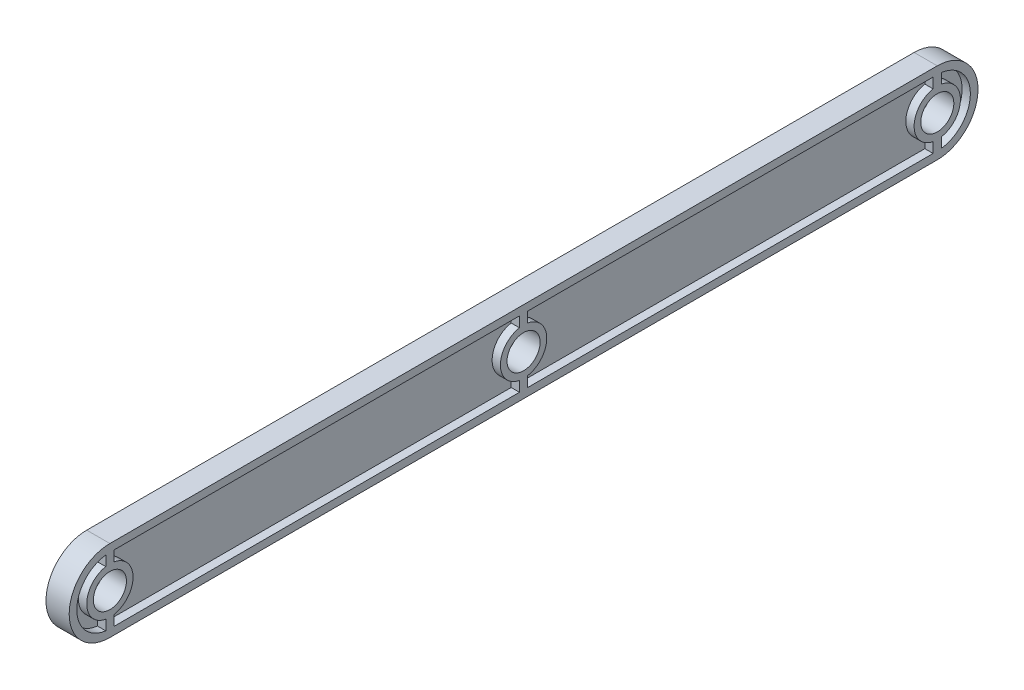
from build123d import *

# Parameters (mm, degrees)
BOSS_EXTRUDE1_DEPTH = 2
EXTRUDE_START       = 5
EXTRUDE_1_DEPTH     = 5
EXTRUDE_2_DEPTH     = 5
SKETCH_4_R          = 14
SKETCH_4_R_2        = 14.00018903
CUT_EXTRUDE_1_DEPTH = 5
SKETCH1_3_R         = 10
CUT_EXTRUDE_2_DEPTH = 15
RIB_2_REACH         = 478.571
SKETCH_5_WALLS_W    = 5
SKETCH_5_WALLS_H    = 961.14191471
SKETCH_5_WALLS_H_2  = 961.14172568


with BuildPart() as part:
    # Sketch1 → Boss-Extrude1 (new, symmetric)
    with BuildSketch(Plane(origin=(0, 0, 0), x_dir=(0, 0, -1), z_dir=(1, 0, 0))):
        with BuildLine():
            Line((451.121433311, 24.607830126), (-48.878566689, 24.607830126))
            ThreePointArc((-48.878566689, 24.607830126), (-73.486396815, 0), (-48.878566689, -24.607830126))
            Line((-48.878566689, -24.607830126), (451.121433311, -24.607830126))
            ThreePointArc((451.121433311, -24.607830126), (475.729263437, 0), (451.121433311, 24.607830126))
        make_face()
    extrude(amount=BOSS_EXTRUDE1_DEPTH, both=True)

    # Sketch 1 → Extrude 1 (add)
    with BuildSketch(Plane(origin=(2, 0, 0), x_dir=(0, 0, -1), z_dir=(1, 0, 0)).offset(EXTRUDE_START)):
        with BuildLine():
            Line((451.121433311, 24.607830126), (-48.878566689, 24.607830126))
            ThreePointArc((-48.878566689, 24.607830126), (-73.486396815, 0), (-48.878566689, -24.607830126))
            Line((-48.878566689, -24.607830126), (451.121433311, -24.607830126))
            ThreePointArc((451.121433311, -24.607830126), (475.729263437, 0), (451.121433311, 24.607830126))
        make_face()
    extrude(amount=-EXTRUDE_1_DEPTH)

    # Sketch 2 → Extrude 2 (add)
    with BuildSketch(Plane.ZY.offset(2)):
        with BuildLine():
            Line((-451.121433311, 24.607830126), (48.878566689, 24.607830126))
            ThreePointArc((48.878566689, 24.607830126), (73.486396815, 0), (48.878566689, -24.607830126))
            Line((48.878566689, -24.607830126), (-451.121433311, -24.607830126))
            ThreePointArc((-451.121433311, -24.607830126), (-475.729263437, 0), (-451.121433311, 24.607830126))
        make_face()
    extrude(amount=EXTRUDE_2_DEPTH)

    # Sketch 4 → Cut-Extrude 1 (cut)
    with BuildSketch(Plane.ZY.offset(7)):
        with BuildLine():
            Line((48.878566689, 20), (-451.121433311, 20))
            ThreePointArc((-451.121433311, 20), (-471.121433311, 0), (-451.121433311, -20))
            Line((-451.121433311, -20), (48.878566689, -20))
            ThreePointArc((48.878566689, -20), (68.878566689, 0), (48.878566689, 20))
        make_face()
        with Locations((-451.121433311, 0)):
            Circle(SKETCH_4_R, mode=Mode.SUBTRACT)
        with Locations((-201.121433311, 0)):
            Circle(SKETCH_4_R_2, mode=Mode.SUBTRACT)
        with Locations((48.878566689, 0)):
            Circle(SKETCH_4_R, mode=Mode.SUBTRACT)
    cut_extrude_1 = extrude(amount=-CUT_EXTRUDE_1_DEPTH, mode=Mode.SUBTRACT)

    # Mirror 1: Cut-Extrude 1 across plane
    add(cut_extrude_1.mirror(Plane.ZY), mode=Mode.SUBTRACT)

    # Sketch1_3 → Cut-Extrude 2 (cut, symmetric)
    with BuildSketch(Plane(origin=(0, 0, 0), x_dir=(0, 0, -1), z_dir=(1, 0, 0))):
        with Locations((451.121433311, 0)):
            Circle(SKETCH1_3_R)
        with Locations((201.121433311, 0)):
            Circle(SKETCH1_3_R)
        with Locations((-48.878566689, 0)):
            Circle(SKETCH1_3_R)
    extrude(amount=CUT_EXTRUDE_2_DEPTH, both=True, mode=Mode.SUBTRACT)

    # Sketch 5 walls → Rib 2 (add, up to next)
    with BuildSketch(Plane.ZY.offset(7), mode=Mode.PRIVATE) as rib_2_sk1:
        with Locations((48.878566689, 17)):
            Rectangle(SKETCH_5_WALLS_W, SKETCH_5_WALLS_H)
    rib_2_tool1 = extrude(rib_2_sk1.sketch, amount=-RIB_2_REACH, mode=Mode.PRIVATE) - part.part
    # Sketch 5 walls → Rib 2 (add, up to next)
    with BuildSketch(Plane.ZY.offset(7), mode=Mode.PRIVATE) as rib_2_sk2:
        with Locations((48.878566689, -17)):
            Rectangle(SKETCH_5_WALLS_W, SKETCH_5_WALLS_H)
    rib_2_tool2 = extrude(rib_2_sk2.sketch, amount=-RIB_2_REACH, mode=Mode.PRIVATE) - part.part
    # Sketch 5 walls → Rib 2 (add, up to next)
    with BuildSketch(Plane.ZY.offset(7), mode=Mode.PRIVATE) as rib_2_sk3:
        with Locations((-201.121433311, -17.000094515)):
            Rectangle(SKETCH_5_WALLS_W, SKETCH_5_WALLS_H_2)
    rib_2_tool3 = extrude(rib_2_sk3.sketch, amount=-RIB_2_REACH, mode=Mode.PRIVATE) - part.part
    # Sketch 5 walls → Rib 2 (add, up to next)
    with BuildSketch(Plane.ZY.offset(7), mode=Mode.PRIVATE) as rib_2_sk4:
        with Locations((-201.121433311, 17.000094515)):
            Rectangle(SKETCH_5_WALLS_W, SKETCH_5_WALLS_H_2)
    rib_2_tool4 = extrude(rib_2_sk4.sketch, amount=-RIB_2_REACH, mode=Mode.PRIVATE) - part.part
    # Sketch 5 walls → Rib 2 (add, up to next)
    with BuildSketch(Plane.ZY.offset(7), mode=Mode.PRIVATE) as rib_2_sk5:
        with Locations((-451.121433311, 17)):
            Rectangle(SKETCH_5_WALLS_W, SKETCH_5_WALLS_H)
    rib_2_tool5 = extrude(rib_2_sk5.sketch, amount=-RIB_2_REACH, mode=Mode.PRIVATE) - part.part
    # Sketch 5 walls → Rib 2 (add, up to next)
    with BuildSketch(Plane.ZY.offset(7), mode=Mode.PRIVATE) as rib_2_sk6:
        with Locations((-451.121433311, -17)):
            Rectangle(SKETCH_5_WALLS_W, SKETCH_5_WALLS_H)
    rib_2_tool6 = extrude(rib_2_sk6.sketch, amount=-RIB_2_REACH, mode=Mode.PRIVATE) - part.part
    rib_2_1 = rib_2_tool1.solids().sort_by_distance((-7, 17, 48.878566689))[0]
    add(rib_2_1)
    rib_2_2 = rib_2_tool2.solids().sort_by_distance((-7, -17, 48.878566689))[0]
    add(rib_2_2)
    rib_2_3 = rib_2_tool3.solids().sort_by_distance((-7, -17.000094515, -201.121433311))[0]
    add(rib_2_3)
    rib_2_4 = rib_2_tool4.solids().sort_by_distance((-7, 17.000094515, -201.121433311))[0]
    add(rib_2_4)
    rib_2_5 = rib_2_tool5.solids().sort_by_distance((-7, 17, -451.121433311))[0]
    add(rib_2_5)
    rib_2_6 = rib_2_tool6.solids().sort_by_distance((-7, -17, -451.121433311))[0]
    add(rib_2_6)
    rib_2 = rib_2_1 + rib_2_2 + rib_2_3 + rib_2_4 + rib_2_5 + rib_2_6  # Rib 2 as one shape, for the pattern or mirror that repeats it

    # Mirror 2: Rib 2 across plane
    add(rib_2.mirror(Plane.ZY))


solid = part.part
